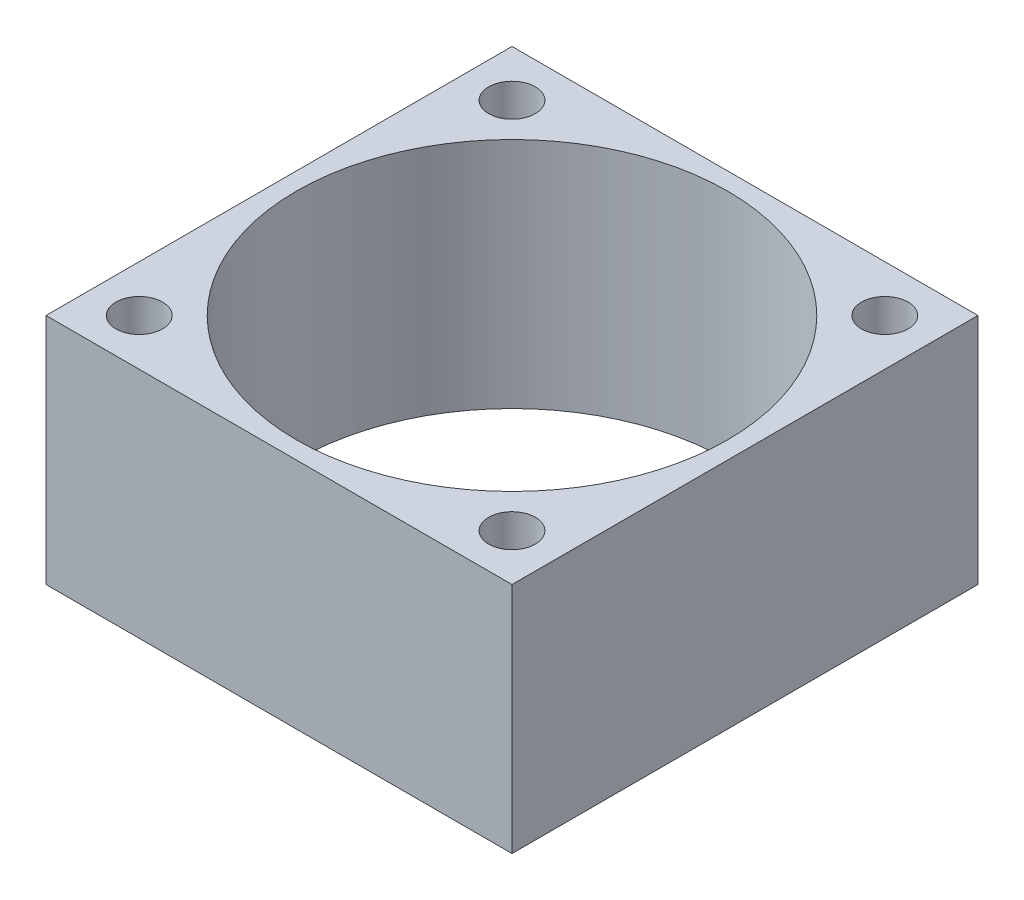
from build123d import *

# Parameters (mm, degrees)
SKETCH1_W           = 40
SKETCH1_H           = 40
BOSS_EXTRUDE1_DEPTH = 20
SKETCH2_R           = 2
SKETCH2_R_2         = 18.5
CUT_EXTRUDE2_DEPTH  = 20


with BuildPart() as part:
    # Sketch1 → Boss-Extrude1 (new body)
    with BuildSketch(Plane(origin=(0, 0, 0), x_dir=(1, 0, 0), z_dir=(0, 1, 0))):
        with Locations((-20, -20)):
            Rectangle(SKETCH1_W, SKETCH1_H)
    extrude(amount=BOSS_EXTRUDE1_DEPTH)

    # Sketch2 → Cut-Extrude2 (cut)
    with BuildSketch(Plane(origin=(0, 20, 0), x_dir=(1, 0, 0), z_dir=(0, 1, 0))):
        with Locations((-36, -4)):
            Circle(SKETCH2_R)
        with Locations((-4, -4)):
            Circle(SKETCH2_R)
        with Locations((-4, -36)):
            Circle(SKETCH2_R)
        with Locations((-36, -36)):
            Circle(SKETCH2_R)
        with Locations((-20, -20)):
            Circle(SKETCH2_R_2)
    extrude(amount=-CUT_EXTRUDE2_DEPTH, mode=Mode.SUBTRACT)


solid = part.part
